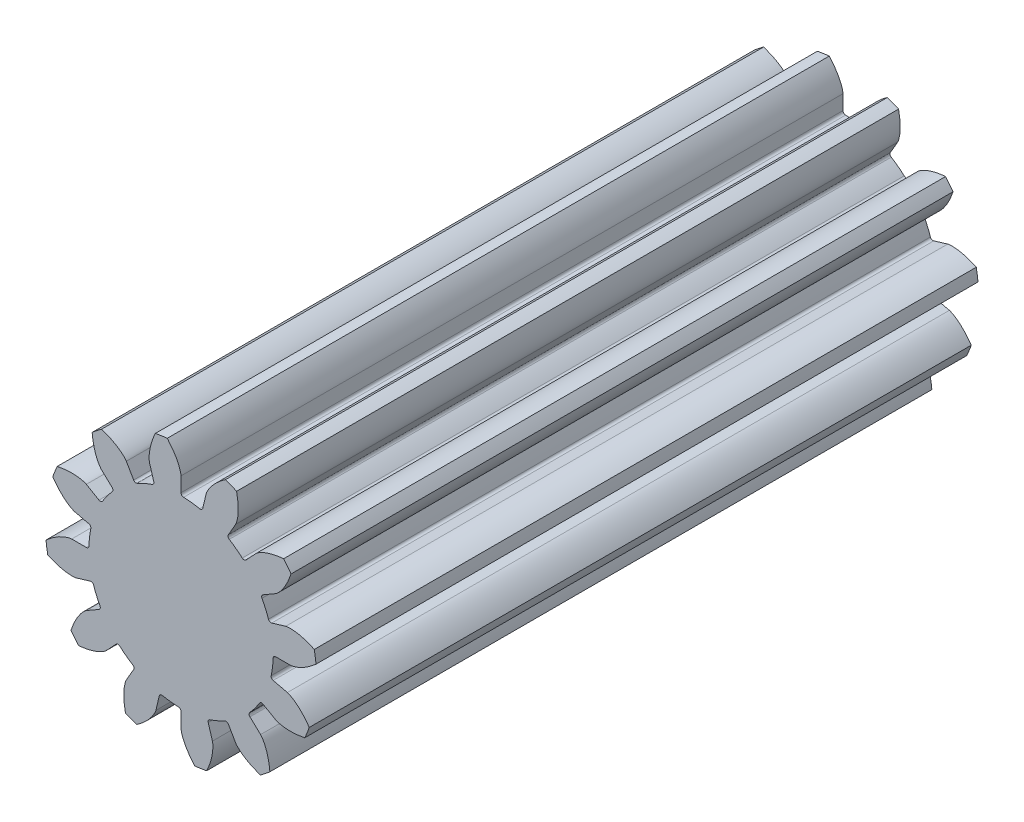
from build123d import *

# Parameters (mm, degrees)
SKETCH1_R                = 5.207000223
BOSS_EXTRUDE1_DEPTH      = 25.4
CUT_EXTRUDE1_START       = -26.4
CUT_EXTRUDE1_DEPTH       = 27.4
FILLET1_R                = 0.1016
CIRPATTERN1_COUNT        = 12
FILLET1_OF_CIRPATTERN1_R = 0.1016


with BuildPart() as part:
    # Sketch1 → Boss-Extrude1 (new body)
    with BuildSketch(Plane.XY):
        Circle(SKETCH1_R)
    extrude(amount=-BOSS_EXTRUDE1_DEPTH)

    # Sketch2 → Cut-Extrude1 (cut)
    with BuildSketch(Plane.XY.offset(CUT_EXTRUDE1_START)):
        with BuildLine():
            Line((4.193982588, 0), (3.53332158, 0))
            ThreePointArc((3.53332158, 0), (3.509577955, -0.40893027), (3.43866619, -0.812364587))
            Line((3.43866619, -0.812364587), (4.081628519, -0.964260641))
            add(Edge.make_bspline(
                [(4.081628519, -0.964260641), (4.084630994, -0.965037379), (4.092998922, -0.967411994), (4.10859931, -0.97267296), (4.133686922, -0.982336061), (4.165070392, -0.996217063), (4.204887745, -1.015928565), (4.250763933, -1.041391125), (4.300012413, -1.071677614), (4.352243513, -1.107061101), (4.403090912, -1.14447189), (4.452579509, -1.183711719), (4.500725081, -1.224506867), (4.55762093, -1.27588703), (4.623823015, -1.340198833), (4.698101278, -1.419157882), (4.77856007, -1.513073217), (4.844331784, -1.597792698), (4.888389543, -1.658408605), (4.913339832, -1.694236281), (4.920211604, -1.704220965)],
                knots=[0, 0, 0, 0, 0, 0.005376748, 0.015083688, 0.02853182, 0.046610139, 0.064854849, 0.092110525, 0.119476175, 0.146842495, 0.174208853, 0.201574955, 0.228941013, 0.256307345, 0.307035032, 0.361767351, 0.41649966, 0.471231936, 0.492236381, 0.492236381, 0.492236381, 0.492236381, 0.492236381], degree=4))
            ThreePointArc((4.920211604, -1.704220965), (5.13480254, -0.864091547), (5.207000223, 0))
            ThreePointArc((5.207000223, 0), (5.200303049, 0.264006667), (5.180228755, 0.527334211))
            add(Edge.make_bspline(
                [(4.193982588, 0), (4.197083213, 6.5615e-05), (4.20577293, 0.000452701), (4.22216497, 0.001985962), (4.248802195, 0.005622169), (4.282536377, 0.011915769), (4.325819025, 0.021944596), (4.376320451, 0.036177394), (4.431212922, 0.05432955), (4.490179988, 0.076756409), (4.54826653, 0.101474394), (4.605451196, 0.128284829), (4.661686407, 0.1569177), (4.728871137, 0.193840197), (4.808085978, 0.241208258), (4.898528265, 0.300974338), (4.998424187, 0.373875038), (5.081912223, 0.441203017), (5.138726225, 0.490065512), (5.171245442, 0.519196935), (5.180228755, 0.527334211)],
                knots=[0, 0, 0, 0, 0, 0.005376748, 0.015083688, 0.02853182, 0.046610139, 0.064854849, 0.092110525, 0.119476175, 0.146842495, 0.174208853, 0.201574955, 0.228941013, 0.256307345, 0.307035032, 0.361767351, 0.41649966, 0.471231936, 0.492236381, 0.492236381, 0.492236381, 0.492236381, 0.492236381], degree=4))
        make_face()
    cut_extrude1 = extrude(amount=CUT_EXTRUDE1_DEPTH, mode=Mode.SUBTRACT)

    # Fillet1
    fillet1_edges = [part.edges().sort_by_distance(p)[0] for p in [
        (3.53332158, 0, -12.7),
        (3.43866619, -0.812364587, -12.7),
    ]]
    fillet(fillet1_edges, radius=FILLET1_R)

    # CirPattern1: Cut-Extrude1 ×12 about axis
    cirpattern1_axis = Axis((0, 0, -25.4), (0, 0, 1))
    for i in range(1, CIRPATTERN1_COUNT):
        add(cut_extrude1.rotate(cirpattern1_axis, i * 360 / CIRPATTERN1_COUNT), mode=Mode.SUBTRACT)

    # Fillet1 of CirPattern1
    fillet1_of_cirpattern1_edges = [part.edges().sort_by_distance(p)[0] for p in [
        (3.059946248, 1.76666079, -12.7),
        (3.384154569, 1.015804726, -12.7),
        (1.76666079, 3.059946248, -12.7),
        (2.422861464, 2.571789982, -12.7),
        (0, 3.53332158, -12.7),
        (0.812364587, 3.43866619, -12.7),
        (-1.76666079, 3.059946248, -12.7),
        (-1.015804726, 3.384154569, -12.7),
        (-3.059946248, 1.76666079, -12.7),
        (-2.571789982, 2.422861464, -12.7),
        (-3.53332158, 0, -12.7),
        (-3.43866619, 0.812364587, -12.7),
        (-3.059946248, -1.76666079, -12.7),
        (-3.384154569, -1.015804726, -12.7),
        (-1.76666079, -3.059946248, -12.7),
        (-2.422861464, -2.571789982, -12.7),
        (0, -3.53332158, -12.7),
        (-0.812364587, -3.43866619, -12.7),
        (1.76666079, -3.059946248, -12.7),
        (1.015804726, -3.384154569, -12.7),
        (3.059946248, -1.76666079, -12.7),
        (2.571789982, -2.422861464, -12.7),
    ]]
    fillet(fillet1_of_cirpattern1_edges, radius=FILLET1_OF_CIRPATTERN1_R)


solid = part.part
